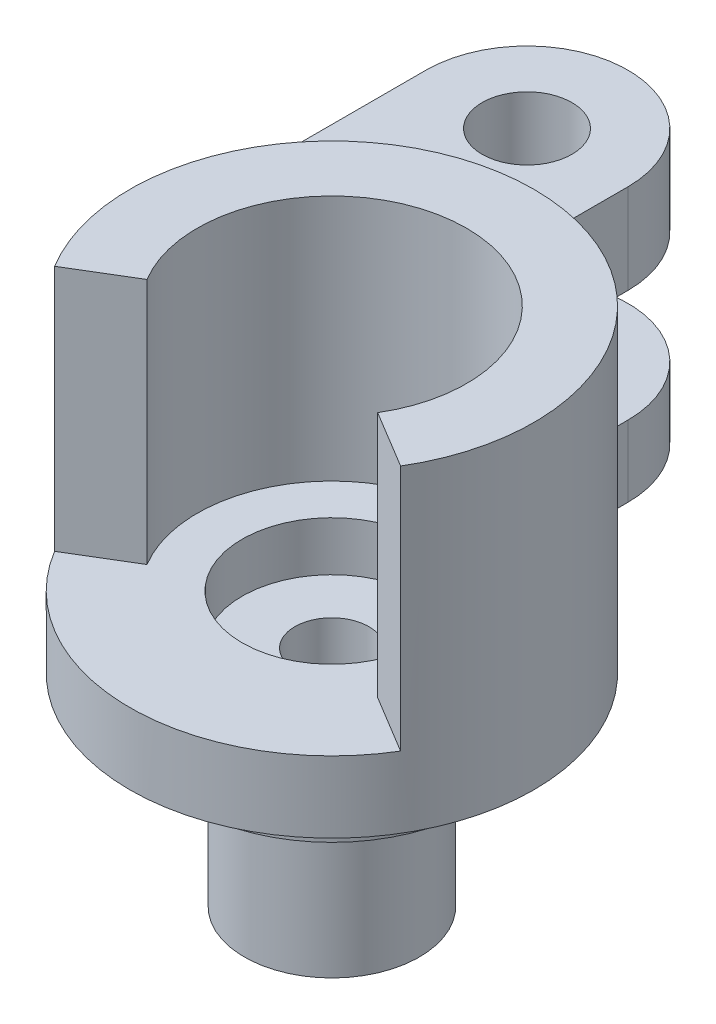
from build123d import *

# Parameters (mm, degrees)
SKETCH1_R           = 9
BOSS_EXTRUDE1_DEPTH = 3.175
BOSS_EXTRUDE2_DEPTH = 11
SKETCH3_R           = 6.399999954
BOSS_EXTRUDE3_DEPTH = 2
SKETCH4_R           = 3.899999974
BOSS_EXTRUDE4_DEPTH = 6.999999906
BOSS_EXTRUDE5_DEPTH = 3.175
BOSS_EXTRUDE7_DEPTH = 4
SKETCH8_R           = 2
CUT_EXTRUDE1_DEPTH  = 4
SKETCH9_R           = 1.650000048
CUT_EXTRUDE2_DEPTH  = 12.175
SKETCH10_R          = 4
CUT_EXTRUDE3_DEPTH  = 2.2
SKETCH11_R          = 1.7145
CUT_EXTRUDE4_DEPTH  = 1.5


with BuildPart() as part:
    # Sketch1 → Boss-Extrude1 (new body)
    with BuildSketch(Plane(origin=(0, 0, 0), x_dir=(1, 0, 0), z_dir=(0, 1, 0))):
        Circle(SKETCH1_R)
    extrude(amount=BOSS_EXTRUDE1_DEPTH)

    # Sketch2 → Boss-Extrude2 (add)
    with BuildSketch(Plane(origin=(0, 3.175, 0), x_dir=(1, 0, 0), z_dir=(0, 1, 0))):
        with BuildLine():
            Line((-7.707704384, -4.646643211), (-5.138469589, -3.097762141))
            ThreePointArc((-5.138469589, -3.097762141), (0, 6), (5.138469589, -3.097762141))
            Line((5.138469589, -3.097762141), (7.707704384, -4.646643211))
            ThreePointArc((7.707704384, -4.646643211), (0, 9), (-7.707704384, -4.646643211))
        make_face()
    extrude(amount=BOSS_EXTRUDE2_DEPTH)

    # Sketch3 → Boss-Extrude3 (add)
    with BuildSketch(Plane.XZ):
        Circle(SKETCH3_R)
    extrude(amount=BOSS_EXTRUDE3_DEPTH)

    # Sketch4 → Boss-Extrude4 (add)
    with BuildSketch(Plane.XZ.offset(2)):
        Circle(SKETCH4_R)
    extrude(amount=BOSS_EXTRUDE4_DEPTH)

    # Sketch6 → Boss-Extrude5 (add)
    with BuildSketch(Plane(origin=(0, 0, 0), x_dir=(1, 0, 0), z_dir=(0, 1, 0))):
        with BuildLine():
            Line((-9, 0), (-9, 13.194197425))
            ThreePointArc((-9, 13.194197425), (-4.5, 17.694197425), (0, 13.194197425))
            Line((0, 13.194197425), (0, 9))
            ThreePointArc((0, 9), (-6.363961031, 6.363961031), (-9, 0))
        make_face()
    extrude(amount=BOSS_EXTRUDE5_DEPTH)

    # Sketch7 → Boss-Extrude7 (add)
    with BuildSketch(Plane(origin=(0, 8.174999906, 0), x_dir=(1, 0, 0), z_dir=(0, 1, 0))):
        with BuildLine():
            Line((0, 9), (0, 13.194197425))
            ThreePointArc((0, 13.194197425), (-4.5, 17.694197425), (-9, 13.194197425))
            Line((-9, 13.194197425), (-9, 0))
            ThreePointArc((-9, 0), (-6.363961031, 6.363961031), (0, 9))
        make_face()
    extrude(amount=BOSS_EXTRUDE7_DEPTH)

    # Sketch8 → Cut-Extrude1 (cut)
    with BuildSketch(Plane(origin=(0, 12.174999906, 0), x_dir=(1, 0, 0), z_dir=(0, 1, 0))):
        with Locations((-4.5, 13.194197425)):
            Circle(SKETCH8_R)
    extrude(amount=-CUT_EXTRUDE1_DEPTH, mode=Mode.SUBTRACT)

    # Sketch9 → Cut-Extrude2 (cut)
    with BuildSketch(Plane(origin=(0, 3.175, 0), x_dir=(1, 0, 0), z_dir=(0, 1, 0))):
        Circle(SKETCH9_R)
    extrude(amount=-CUT_EXTRUDE2_DEPTH, mode=Mode.SUBTRACT)

    # Sketch10 → Cut-Extrude3 (cut)
    with BuildSketch(Plane(origin=(0, 3.175, 0), x_dir=(1, 0, 0), z_dir=(0, 1, 0))):
        Circle(SKETCH10_R)
    extrude(amount=-CUT_EXTRUDE3_DEPTH, mode=Mode.SUBTRACT)

    # Sketch11 → Cut-Extrude4 (cut)
    with BuildSketch(Plane(origin=(0, 3.175, 0), x_dir=(1, 0, 0), z_dir=(0, 1, 0))):
        with Locations((-4.5, 13.194197425)):
            Circle(SKETCH11_R)
    extrude(amount=-CUT_EXTRUDE4_DEPTH, mode=Mode.SUBTRACT)


solid = part.part
